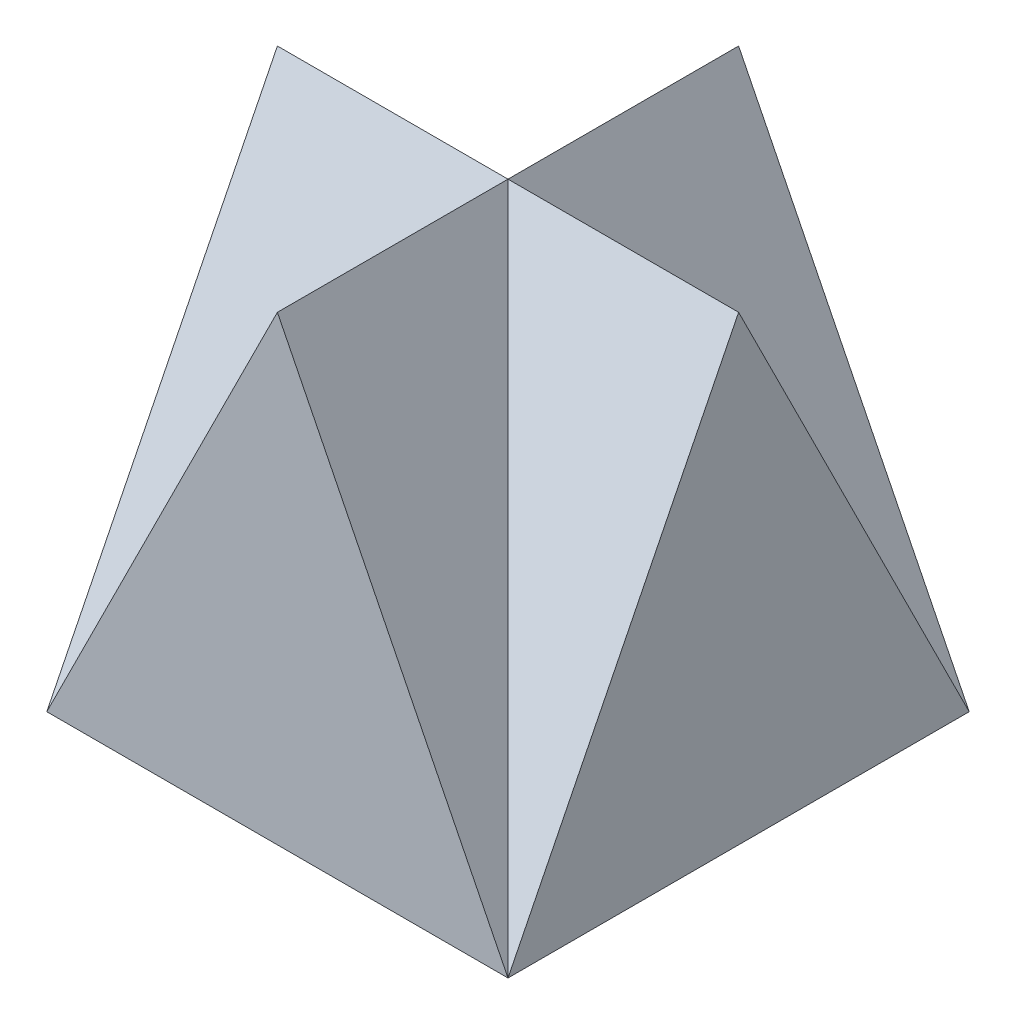
from build123d import *

# Parameters (mm, degrees)
SKETCH1_W           = 4
SKETCH1_H           = 4
BOSS_EXTRUDE1_DEPTH = 4
CUT_EXTRUDE5_DEPTH  = 32
CUT_EXTRUDE6_DEPTH  = 32
CUT_EXTRUDE7_DEPTH  = 32
CUT_EXTRUDE8_DEPTH  = 32


with BuildPart() as part:
    # Sketch1 → Boss-Extrude1 (new body)
    with BuildSketch(Plane(origin=(0, 0, 0), x_dir=(1, 0, 0), z_dir=(0, 1, 0))):
        Rectangle(SKETCH1_W, SKETCH1_H)
    extrude(amount=BOSS_EXTRUDE1_DEPTH)

    # 3DSketch3 → Cut-Extrude5 (cut, along a direction that is not the sketch's normal)
    with BuildSketch(Plane(origin=(0, 4, 0), x_dir=(-0.4082482904638629, -0.8164965809277258, 0.40824829046386363), z_dir=(-0.894427190999916, 0.447213595499958, 0))):
        Polygon((0, 0), (0.816496581, 1.825741858), (4.898979486, 0), align=None)
    extrude(amount=CUT_EXTRUDE5_DEPTH, dir=(-1, 0, 0), mode=Mode.SUBTRACT)

    # 3DSketch4 → Cut-Extrude6 (cut, along a direction that is not the sketch's normal)
    with BuildSketch(Plane(origin=(0, 4, 0), x_dir=(-0.4082482904638631, -0.8164965809277261, -0.4082482904638631), z_dir=(0, 0.447213595499958, -0.894427190999916))):
        Polygon((0, 0), (0.816496581, 1.825741858), (4.898979486, 0), align=None)
    extrude(amount=CUT_EXTRUDE6_DEPTH, dir=(0, 1, 0), mode=Mode.SUBTRACT)

    # 3DSketch5 → Cut-Extrude7 (cut, along a direction that is not the sketch's normal)
    with BuildSketch(Plane(origin=(0, 4, 0), x_dir=(-0.4082482904638631, -0.816496580927726, -0.4082482904638631), z_dir=(0.894427190999916, -0.447213595499958, 0))):
        Polygon((0, 0), (4.898979486, 0), (0.816496581, 1.825741858), align=None)
    extrude(amount=-CUT_EXTRUDE7_DEPTH, dir=(1, 0, 0), mode=Mode.SUBTRACT)

    # 3DSketch6 → Cut-Extrude8 (cut, along a direction that is not the sketch's normal)
    with BuildSketch(Plane(origin=(2, 0, 2), x_dir=(-0.3333333333333332, 0.6666666666666664, -0.666666666666667), z_dir=(0.894427190999916, 0.447213595499958, 0))):
        Polygon((3.333333333, 2.98142397), (0, 0), (4.666666667, 1.490711985), align=None)
        Polygon((6, 0), (4.666666667, 1.490711985), (2.666666667, -2.98142397), align=None)
    extrude(amount=CUT_EXTRUDE8_DEPTH, dir=(1, 0, 0), mode=Mode.SUBTRACT)


solid = part.part
